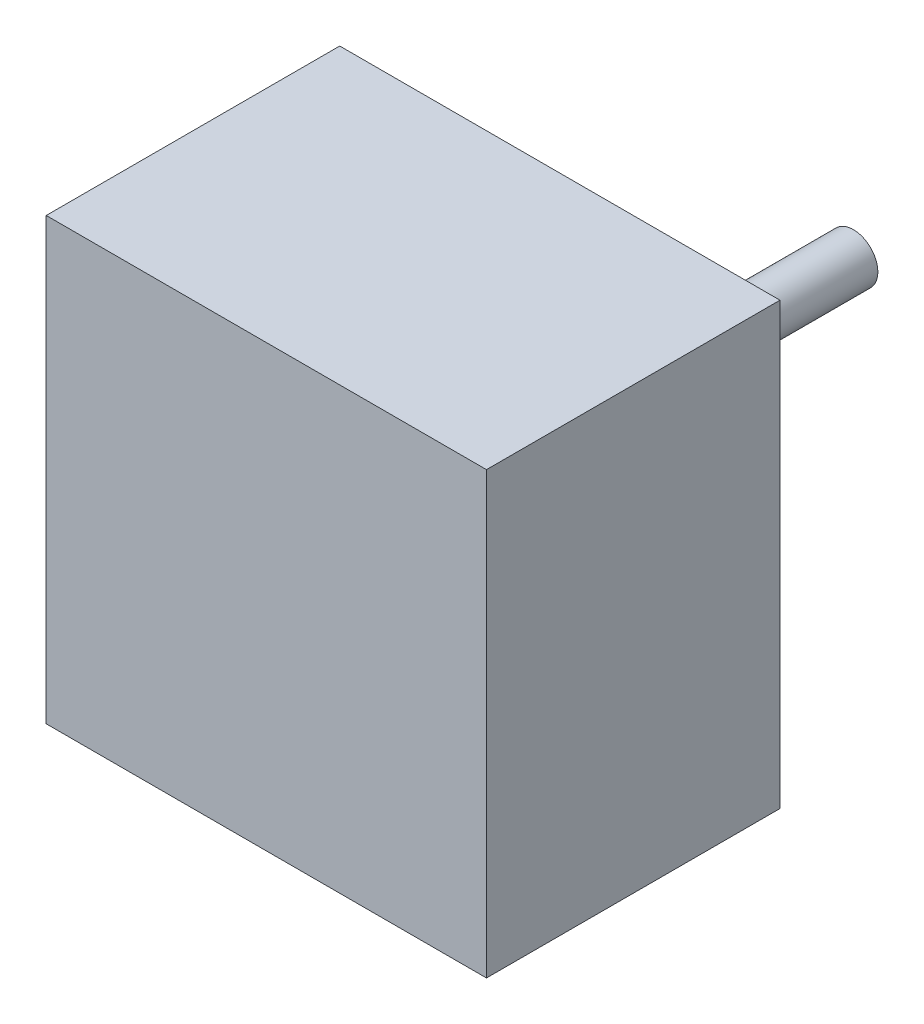
from build123d import *

# Parameters (mm, degrees)
SKETCH1_R           = 12.5
BOSS_EXTRUDE1_DEPTH = 10
SKETCH2_W           = 45
SKETCH2_H           = 45
BOSS_EXTRUDE2_DEPTH = 30
SKETCH4_R           = 2.5
BOSS_EXTRUDE3_DEPTH = 20


with BuildPart() as part:
    # Sketch1 → Boss-Extrude1 (new body)
    with BuildSketch(Plane.XY):
        Circle(SKETCH1_R)
    extrude(amount=BOSS_EXTRUDE1_DEPTH)

    # Sketch2 → Boss-Extrude2 (add)
    with BuildSketch(Plane.XY.offset(10)):
        Rectangle(SKETCH2_W, SKETCH2_H)
    extrude(amount=BOSS_EXTRUDE2_DEPTH)

    # Sketch4 → Boss-Extrude3 (add)
    with BuildSketch(Plane(origin=(0, 0, 0), x_dir=(-1, 0, 0), z_dir=(0, 0, -1))):
        Circle(SKETCH4_R)
    extrude(amount=BOSS_EXTRUDE3_DEPTH)


solid = part.part
